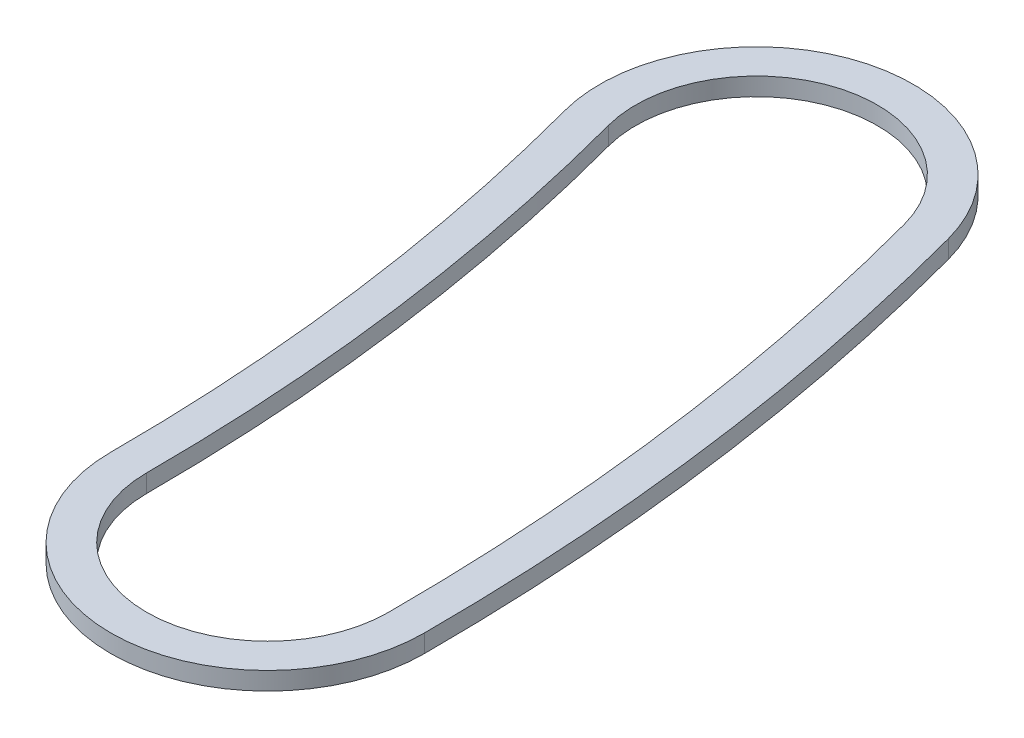
from build123d import *

# Parameters (mm, degrees)
BOSS_EXTRUDE1_DEPTH = 0.508


with BuildPart() as part:
    # Sketch1 → Boss-Extrude1 (new body)
    with BuildSketch(Plane(origin=(0, 0, 0), x_dir=(1, 0, 0), z_dir=(0, 1, 0))):
        with BuildLine():
            ThreePointArc((66.167, 0), (65.600932143, 8.636526561), (63.912414148, 17.125279757))
            ThreePointArc((63.912414148, 17.125279757), (58.468423195, 20.2683694), (55.325333552, 14.824378446))
            ThreePointArc((55.325333552, 14.824378446), (56.786987325, 7.476148712), (57.277, 0))
            ThreePointArc((57.277, 0), (61.722, -4.445), (66.167, 0))
        make_face()
        with BuildLine():
            ThreePointArc((65.151, 0), (64.593624163, 8.503911949), (62.931033509, 16.862319607))
            ThreePointArc((62.931033509, 16.862319607), (58.731383345, 19.28698876), (56.306714192, 15.087338596))
            ThreePointArc((56.306714192, 15.087338596), (57.794295304, 7.608763323), (58.293, 0))
            ThreePointArc((58.293, 0), (61.722, -3.429), (65.151, 0))
        make_face(mode=Mode.SUBTRACT)
    extrude(amount=BOSS_EXTRUDE1_DEPTH)


solid = part.part
